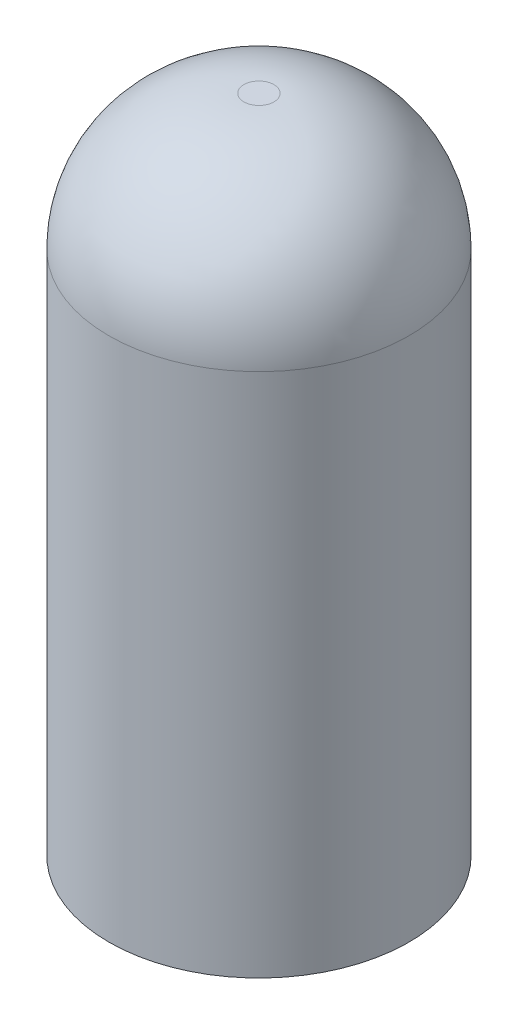
from build123d import *

# Parameters (mm, degrees)
SKETCH1_R           = 6.35
BOSS_EXTRUDE1_DEPTH = 27.94
FILLET1_R           = 5.715
SKETCH2_R           = 1.778
CUT_EXTRUDE1_DEPTH  = 8.255


with BuildPart() as part:
    # Sketch1 → Boss-Extrude1 (new body)
    with BuildSketch(Plane(origin=(0, 0, 0), x_dir=(1, 0, 0), z_dir=(0, 1, 0))):
        Circle(SKETCH1_R)
    extrude(amount=BOSS_EXTRUDE1_DEPTH)

    # Fillet1
    fillet1_edges = [part.edges().sort_by_distance(p)[0] for p in [
        (-6.35, 27.94, 0),
    ]]
    fillet(fillet1_edges, radius=FILLET1_R)

    # Sketch2 → Cut-Extrude1 (cut)
    with BuildSketch(Plane.XZ):
        Circle(SKETCH2_R)
    extrude(amount=-CUT_EXTRUDE1_DEPTH, mode=Mode.SUBTRACT)


solid = part.part
